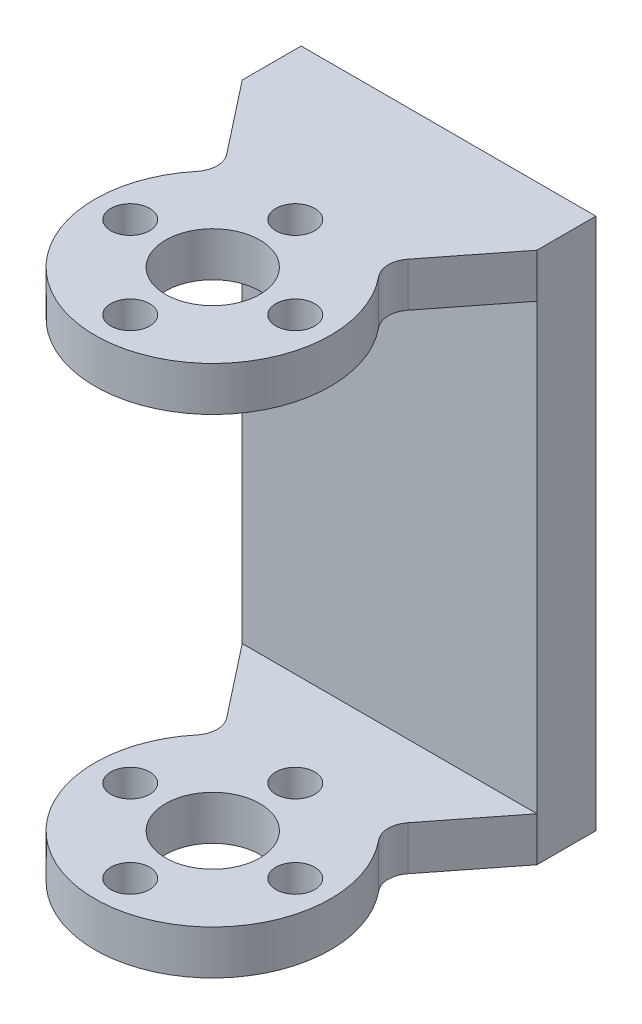
from build123d import *

# Parameters (mm, degrees)
SKETCH1_R           = 4
BOSS_EXTRUDE1_DEPTH = 45.15
SKETCH2_W           = 40
SKETCH2_H           = 37.65
CUT_EXTRUDE1_DEPTH  = 56.34909665
SKETCH3_R           = 1.65
CUT_EXTRUDE2_DEPTH  = 51.93890949
CIRPATTERN1_COUNT   = 4
FILLET1_R           = 2


with BuildPart() as part:
    # Sketch1 → Boss-Extrude1 (new body)
    with BuildSketch(Plane(origin=(0, 0, 0), x_dir=(1, 0, 0), z_dir=(0, 1, 0))):
        with BuildLine():
            Line((-12.5, 15), (-12.5, 20))
            Line((-12.5, 20), (12.5, 20))
            Line((12.5, 20), (12.5, 15))
            Line((12.5, 15), (6.614378278, 7.5))
            ThreePointArc((6.614378278, 7.5), (0, -10), (-6.614378278, 7.5))
            Line((-6.614378278, 7.5), (-12.5, 15))
        make_face()
        Circle(SKETCH1_R, mode=Mode.SUBTRACT)
    extrude(amount=BOSS_EXTRUDE1_DEPTH)

    # Sketch2 → Cut-Extrude1 (cut, through all)
    with BuildSketch(Plane.ZY.offset(12.5)):
        with Locations((5, 22.575)):
            Rectangle(SKETCH2_W, SKETCH2_H)
    extrude(amount=-CUT_EXTRUDE1_DEPTH, mode=Mode.SUBTRACT)

    # Sketch3 → Cut-Extrude2 (cut, through all)
    with BuildSketch(Plane(origin=(0, 45.15, 0), x_dir=(1, 0, 0), z_dir=(0, 1, 0))):
        with Locations((0, 7)):
            Circle(SKETCH3_R)
    cut_extrude2 = extrude(amount=-CUT_EXTRUDE2_DEPTH, mode=Mode.SUBTRACT)

    # CirPattern1: Cut-Extrude2 ×4 about axis
    cirpattern1_axis = Axis((0, 45.15, 0), (0, -1, 0))
    for i in range(1, CIRPATTERN1_COUNT):
        add(cut_extrude2.rotate(cirpattern1_axis, i * 360 / CIRPATTERN1_COUNT), mode=Mode.SUBTRACT)

    # Fillet1
    fillet1_edges = [part.edges().sort_by_distance(p)[0] for p in [
        (6.614378278, 43.275, -7.5),
        (6.614378278, 1.875, -7.5),
        (-6.614378278, 43.275, -7.5),
        (-6.614378278, 1.875, -7.5),
    ]]
    fillet(fillet1_edges, radius=FILLET1_R)


solid = part.part
